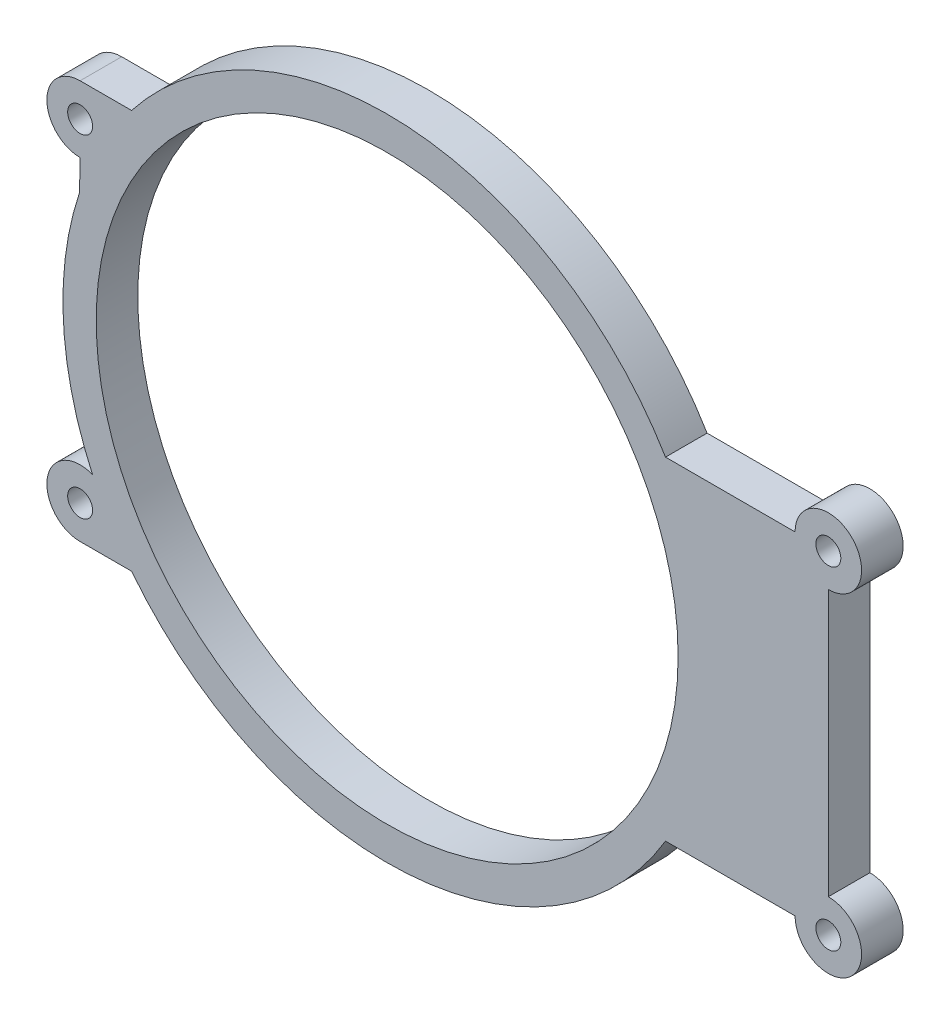
from build123d import *

# Parameters (mm, degrees)
SKETCH1_R           = 1.5
SKETCH1_R_2         = 35
BOSS_EXTRUDE1_DEPTH = 5


with BuildPart() as part:
    # Sketch1 → Boss-Extrude1 (new body)
    with BuildSketch(Plane.XY):
        with BuildLine():
            Line((-30.740852298, 24), (-36.932370625, 24))
            ThreePointArc((-36.932370625, 24), (-40.932370625, 20), (-36.932370625, 16))
            Line((-36.932370625, 16), (-37.002837962, 12.320307738))
            ThreePointArc((-37.002837962, 12.320307738), (-38.941537608, -2.134630811), (-35.434469198, -16.291052533))
            ThreePointArc((-35.434469198, -16.291052533), (-40.858933363, -19.237041898), (-36.932370625, -24))
            Line((-36.932370625, -24), (-30.740852298, -24))
            ThreePointArc((-30.740852298, -24), (2.424369111, -38.924573657), (33.481338086, -20))
            Line((33.481338086, -20), (49.067629375, -20))
            ThreePointArc((49.067629375, -20), (55.8960565, -22.828427125), (53.067629375, -16))
            Line((53.067629375, -16), (53.067629375, 16))
            ThreePointArc((53.067629375, 16), (55.8960565, 22.828427125), (49.067629375, 20))
            Line((49.067629375, 20), (33.481338086, 20))
            ThreePointArc((33.481338086, 20), (2.424369111, 38.924573657), (-30.740852298, 24))
        make_face()
        with Locations((-36.932370625, -20)):
            Circle(SKETCH1_R, mode=Mode.SUBTRACT)
        with Locations((53.067629375, -20)):
            Circle(SKETCH1_R, mode=Mode.SUBTRACT)
        Circle(SKETCH1_R_2, mode=Mode.SUBTRACT)
        with Locations((-36.932370625, 20)):
            Circle(SKETCH1_R, mode=Mode.SUBTRACT)
        with Locations((53.067629375, 20)):
            Circle(SKETCH1_R, mode=Mode.SUBTRACT)
    extrude(amount=BOSS_EXTRUDE1_DEPTH)


solid = part.part
